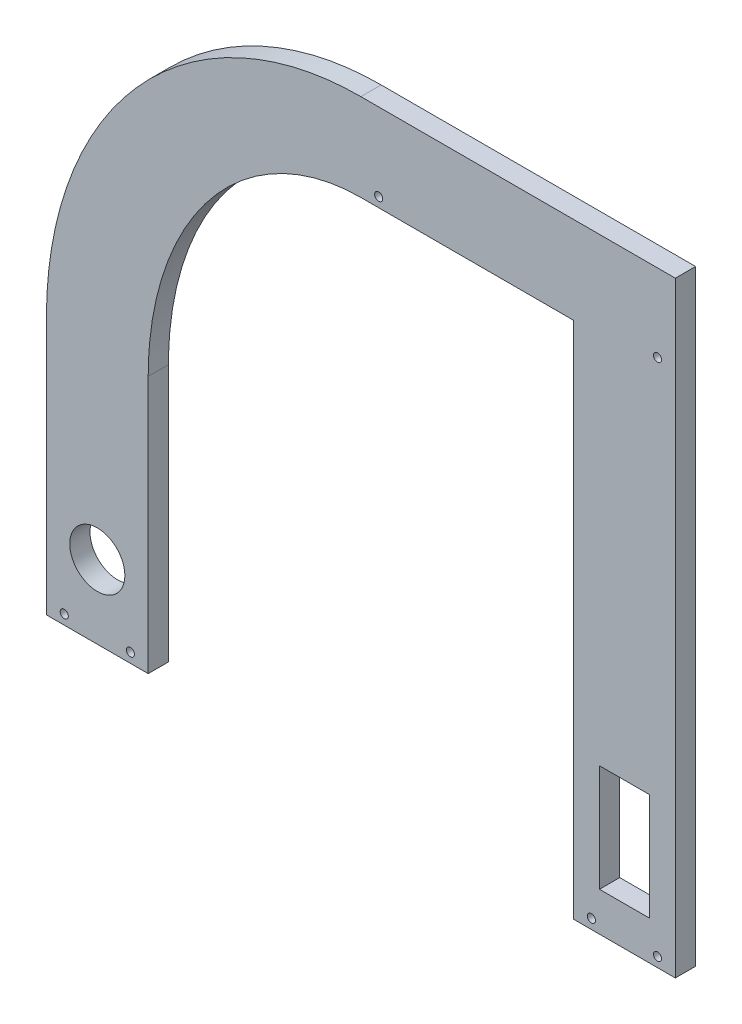
from build123d import *

# Parameters (mm, degrees)
SKETCH2_W           = 246.38
SKETCH2_H           = 254
BOSS_EXTRUDE1_DEPTH = 7.9375
CUT_EXTRUDE2_REACH  = 9.938
SCREW_HOLES_REACH   = 9.938
SKETCH4_R           = 1.5875
CUT_EXTRUDE4_REACH  = 9.938
SKETCH5_R           = 10.795
CUT_EXTRUDE5_REACH  = 9.938
SKETCH6_W           = 19.558
SKETCH6_H           = 41.91


with BuildPart() as part:
    # Sketch2 → Boss-Extrude1 (new body)
    with BuildSketch(Plane.XY):
        with Locations((123.19, 127)):
            Rectangle(SKETCH2_W, SKETCH2_H)
    extrude(amount=BOSS_EXTRUDE1_DEPTH)

    # Sketch3 → Cut-Extrude2 (cut, up to next)
    with BuildSketch(Plane.XY.offset(7.9375), mode=Mode.PRIVATE) as cut_extrude2_sk1:
        with BuildLine():
            Line((0, 254), (0, 100.875137361))
            add(Edge.make_bspline(
                [(123.19, 237.422544345), (0, 237.422544345), (0, 100.875137361)],
                knots=[0, 0, 0, 1.570796327, 1.570796327, 1.570796327], degree=2, weights=[1, 0.707106781, 1]))
            Line((123.19, 237.422544345), (246.38, 237.422544345))
            Line((246.38, 237.422544345), (246.38, 254))
            Line((246.38, 254), (0, 254))
        make_face()
    cut_extrude2_tool1 = extrude(cut_extrude2_sk1.sketch, amount=-CUT_EXTRUDE2_REACH, mode=Mode.PRIVATE) & part.part
    add(cut_extrude2_tool1.solids().sort_by_distance((2.900868, 177.437569, 7.9375))[0], mode=Mode.SUBTRACT)
    # Sketch3 → Cut-Extrude2 (cut, up to next)
    with BuildSketch(Plane.XY.offset(7.9375), mode=Mode.PRIVATE) as cut_extrude2_sk2:
        with BuildLine():
            Line((39.878, 0), (39.878, 100.875137361))
            add(Edge.make_bspline(
                [(123.19, 203.2), (39.878, 203.2), (39.878, 100.875137361)],
                knots=[0, 0, 0, 1.570796327, 1.570796327, 1.570796327], degree=2, weights=[1, 0.707106781, 1]))
            Line((123.19, 203.2), (206.502, 203.2))
            Line((206.502, 203.2), (206.502, 160.284632983))
            Line((206.502, 160.284632983), (206.502, 0))
            Line((206.502, 0), (39.878, 0))
        make_face()
    cut_extrude2_tool2 = extrude(cut_extrude2_sk2.sketch, amount=-CUT_EXTRUDE2_REACH, mode=Mode.PRIVATE) & part.part
    add(cut_extrude2_tool2.solids().sort_by_distance((126.885795, 97.102181, 7.9375))[0], mode=Mode.SUBTRACT)

    # Sketch4 → screw holes (cut, up to next)
    with BuildSketch(Plane.XY.offset(7.9375), mode=Mode.PRIVATE) as screw_holes_sk1:
        with Locations((6.985, 3.81)):
            Circle(SKETCH4_R)
    screw_holes_tool1 = extrude(screw_holes_sk1.sketch, amount=-SCREW_HOLES_REACH, mode=Mode.PRIVATE) & part.part
    add(screw_holes_tool1.solids().sort_by_distance((6.985, 3.81, 7.9375))[0], mode=Mode.SUBTRACT)
    # Sketch4 → screw holes (cut, up to next)
    with BuildSketch(Plane.XY.offset(7.9375), mode=Mode.PRIVATE) as screw_holes_sk2:
        with Locations((32.893, 3.81)):
            Circle(SKETCH4_R)
    screw_holes_tool2 = extrude(screw_holes_sk2.sketch, amount=-SCREW_HOLES_REACH, mode=Mode.PRIVATE) & part.part
    add(screw_holes_tool2.solids().sort_by_distance((32.893, 3.81, 7.9375))[0], mode=Mode.SUBTRACT)
    # Sketch4 → screw holes (cut, up to next)
    with BuildSketch(Plane.XY.offset(7.9375), mode=Mode.PRIVATE) as screw_holes_sk3:
        with Locations((213.487, 3.81)):
            Circle(SKETCH4_R)
    screw_holes_tool3 = extrude(screw_holes_sk3.sketch, amount=-SCREW_HOLES_REACH, mode=Mode.PRIVATE) & part.part
    add(screw_holes_tool3.solids().sort_by_distance((213.487, 3.81, 7.9375))[0], mode=Mode.SUBTRACT)
    # Sketch4 → screw holes (cut, up to next)
    with BuildSketch(Plane.XY.offset(7.9375), mode=Mode.PRIVATE) as screw_holes_sk4:
        with Locations((239.395, 3.81)):
            Circle(SKETCH4_R)
    screw_holes_tool4 = extrude(screw_holes_sk4.sketch, amount=-SCREW_HOLES_REACH, mode=Mode.PRIVATE) & part.part
    add(screw_holes_tool4.solids().sort_by_distance((239.395, 3.81, 7.9375))[0], mode=Mode.SUBTRACT)
    # Sketch4 → screw holes (cut, up to next)
    with BuildSketch(Plane.XY.offset(7.9375), mode=Mode.PRIVATE) as screw_holes_sk5:
        with Locations((130.175, 207.01)):
            Circle(SKETCH4_R)
    screw_holes_tool5 = extrude(screw_holes_sk5.sketch, amount=-SCREW_HOLES_REACH, mode=Mode.PRIVATE) & part.part
    add(screw_holes_tool5.solids().sort_by_distance((130.175, 207.01, 7.9375))[0], mode=Mode.SUBTRACT)
    # Sketch4 → screw holes (cut, up to next)
    with BuildSketch(Plane.XY.offset(7.9375), mode=Mode.PRIVATE) as screw_holes_sk6:
        with Locations((239.395, 207.01)):
            Circle(SKETCH4_R)
    screw_holes_tool6 = extrude(screw_holes_sk6.sketch, amount=-SCREW_HOLES_REACH, mode=Mode.PRIVATE) & part.part
    add(screw_holes_tool6.solids().sort_by_distance((239.395, 207.01, 7.9375))[0], mode=Mode.SUBTRACT)

    # Sketch5 → Cut-Extrude4 (cut, up to next)
    with BuildSketch(Plane.XY.offset(7.9375), mode=Mode.PRIVATE) as cut_extrude4_sk1:
        with Locations((19.939, 28.702)):
            Circle(SKETCH5_R)
    cut_extrude4_tool1 = extrude(cut_extrude4_sk1.sketch, amount=-CUT_EXTRUDE4_REACH, mode=Mode.PRIVATE) & part.part
    add(cut_extrude4_tool1.solids().sort_by_distance((19.939, 28.702, 7.9375))[0], mode=Mode.SUBTRACT)

    # Sketch6 → Cut-Extrude5 (cut, up to next)
    with BuildSketch(Plane.XY.offset(7.9375), mode=Mode.PRIVATE) as cut_extrude5_sk1:
        with Locations((226.441, 36.195)):
            Rectangle(SKETCH6_W, SKETCH6_H)
    cut_extrude5_tool1 = extrude(cut_extrude5_sk1.sketch, amount=-CUT_EXTRUDE5_REACH, mode=Mode.PRIVATE) & part.part
    add(cut_extrude5_tool1.solids().sort_by_distance((226.441, 36.195, 7.9375))[0], mode=Mode.SUBTRACT)


solid = part.part
